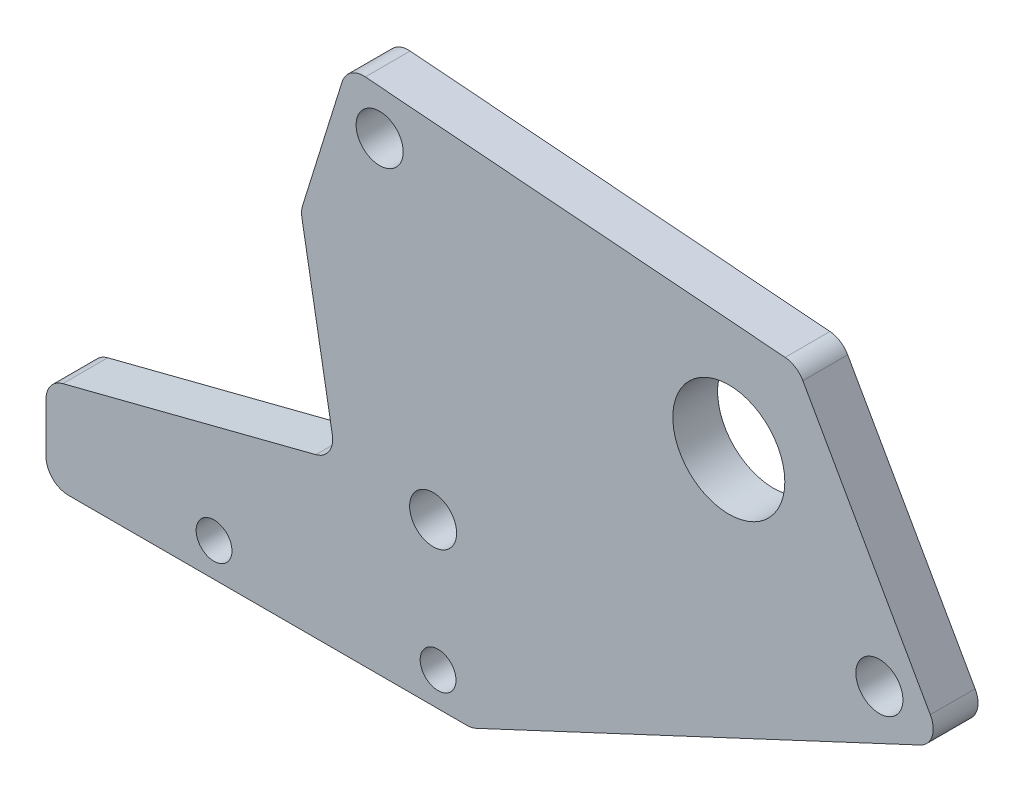
from build123d import *

# Parameters (mm, degrees)
SKETCH1_R           = 2.1
SKETCH1_R_2         = 5
SKETCH1_R_3         = 1.6
BOSS_EXTRUDE1_DEPTH = 4
FILLET1_R           = 2


with BuildPart() as part:
    # Sketch1 → Boss-Extrude1 (new body)
    with BuildSketch(Plane.XY):
        Polygon((0, 0), (-38, 0), (-38, 8), (-12.118525594, 14.647404058), (-15.244192792, 32.373943612), (-11.089131581, 45.719920845), (29.037661116, 42.568648925), (42, 19.629949763), align=None)
        with Locations((-8.219100268, 41.482213208)):
            Circle(SKETCH1_R, mode=Mode.SUBTRACT)
        with Locations((-3.443775383, 14.4)):
            Circle(SKETCH1_R, mode=Mode.SUBTRACT)
        with Locations((36.391698227, 21.424068787)):
            Circle(SKETCH1_R, mode=Mode.SUBTRACT)
        with Locations((22.949568756, 33.015974596)):
            Circle(SKETCH1_R_2, mode=Mode.SUBTRACT)
        with Locations((-23, 3)):
            Circle(SKETCH1_R_3, mode=Mode.SUBTRACT)
        with Locations((-3, 3)):
            Circle(SKETCH1_R_3, mode=Mode.SUBTRACT)
    extrude(amount=BOSS_EXTRUDE1_DEPTH)

    # Fillet1
    fillet1_edges = [part.edges().sort_by_distance(p)[0] for p in [
        (0, 0, 2),
        (-38, 0, 2),
        (-38, 8, 2),
        (-12.118525594, 14.647404058, 2),
        (-15.244192792, 32.373943612, 2),
        (-11.089131581, 45.719920845, 2),
        (29.037661116, 42.568648925, 2),
        (42, 19.629949763, 2),
    ]]
    fillet(fillet1_edges, radius=FILLET1_R)


solid = part.part
